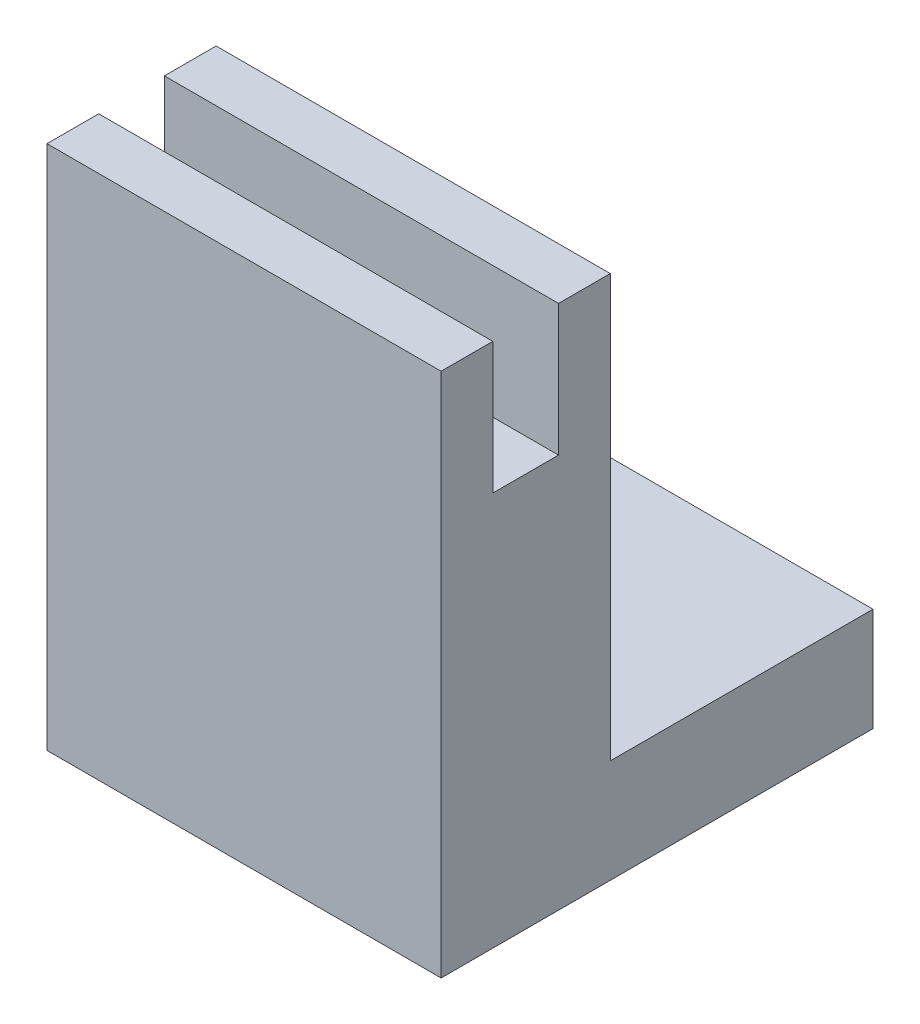
from build123d import *

# Parameters (mm, degrees)
BOSS_EXTRUDE1_DEPTH = 38.1


with BuildPart() as part:
    # Sketch1 → Boss-Extrude1 (new body)
    with BuildSketch(Plane(origin=(0, 0, 0), x_dir=(0, 0, -1), z_dir=(1, 0, 0))):
        Polygon((0, 0), (41.75, 0), (41.75, 10), (16.35, 10), (16.35, 50.8), (11.35, 50.8), (11.35, 38.1), (5, 38.1), (5, 50.8), (0, 50.8), align=None)
    extrude(amount=BOSS_EXTRUDE1_DEPTH)


solid = part.part
